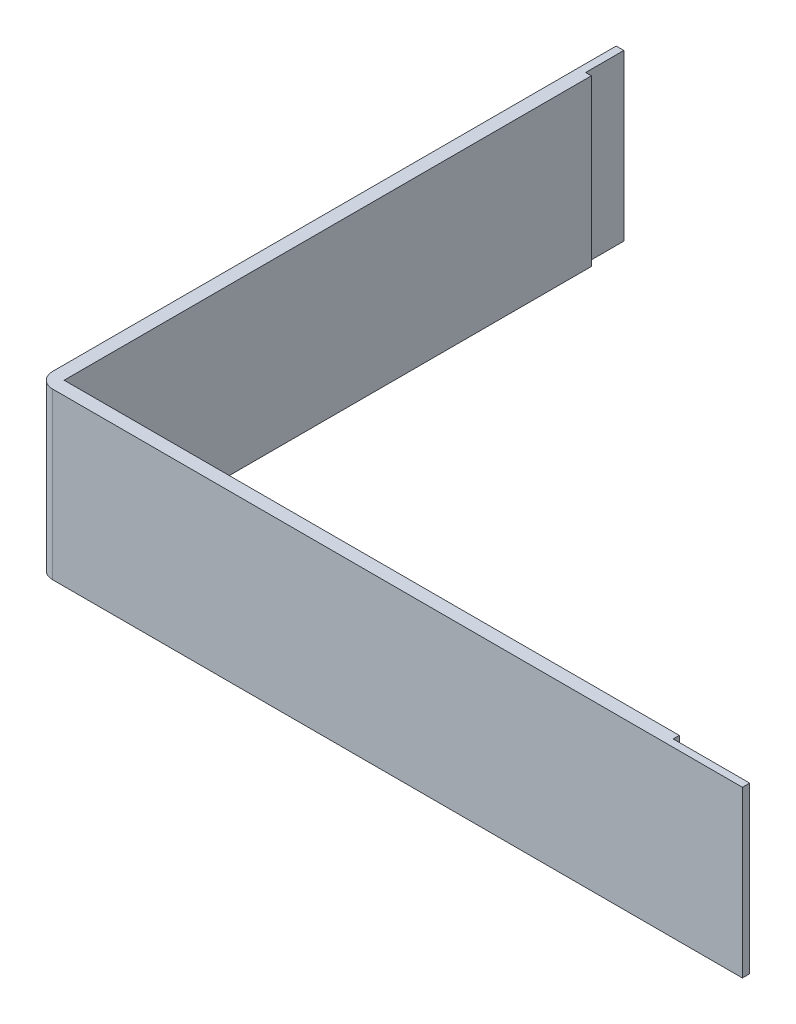
from build123d import *

# Parameters (mm, degrees)
SALIENTE_EXTRUIR1_START = 0.2
SALIENTE_EXTRUIR1_DEPTH = 21.6


with BuildPart() as part:
    # Croquis1 → Saliente-Extruir1 (new body)
    with BuildSketch(Plane(origin=(0, -0.153950711, 0), x_dir=(1, 0, 0), z_dir=(0, 1, 0)).offset(SALIENTE_EXTRUIR1_START)):
        with BuildLine():
            Line((-59.905314299, -154.5), (30.294685701, -154.5))
            Line((30.294685701, -154.5), (30.294685701, -153.55))
            Line((30.294685701, -153.55), (20.294685701, -153.55))
            Line((20.294685701, -153.55), (20.294685701, -152.75))
            Line((20.294685701, -152.75), (-60.155314299, -152.75))
            Line((-60.155314299, -152.75), (-60.155314299, -83.8))
            Line((-60.155314299, -83.8), (-60.905314299, -83.8))
            Line((-60.905314299, -83.8), (-60.905314299, -78.8))
            Line((-60.905314299, -78.8), (-61.905314299, -78.8))
            Line((-61.905314299, -78.8), (-61.905314299, -152.5))
            ThreePointArc((-61.905314299, -152.5), (-61.319527861, -153.914213562), (-59.905314299, -154.5))
        make_face()
    extrude(amount=SALIENTE_EXTRUIR1_DEPTH)


solid = part.part
